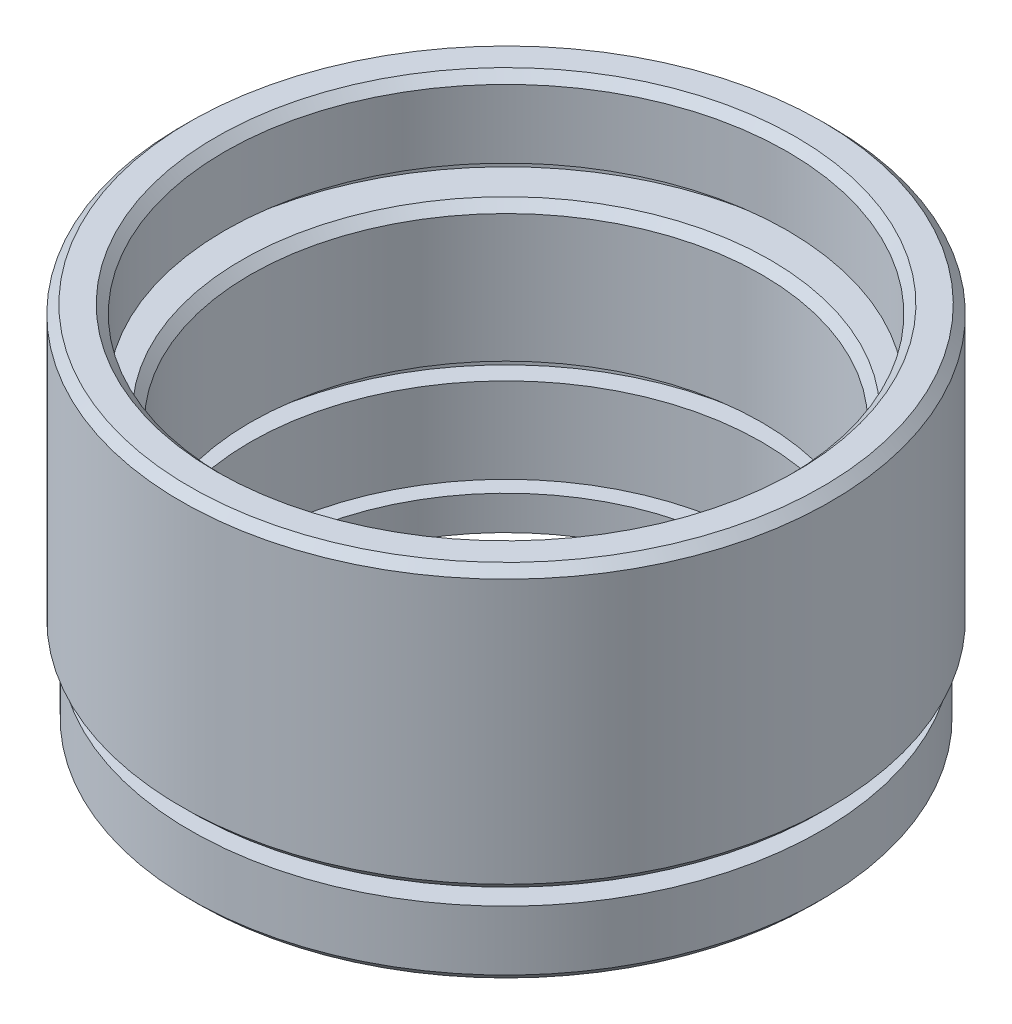
from build123d import *

# Parameters (mm, degrees)
CHAMFER_1_SIZE = 0.5


with BuildPart() as part:
    # 草图1 → 旋转1 (revolve)
    with BuildSketch(Plane.XY, mode=Mode.PRIVATE) as revolve_1_sk:
        Polygon((14, 0), (14, 2), (15, 2), (15, 7), (16.15, 7), (16.15, 8), (15, 8), (15, 16), (17.65, 16), (17.65, 17), (16.5, 17), (16.5, 21.5), (18.55, 21.5), (19.05, 21), (19.05, 5.5), (18.55, 5), (17, 5), (17, 4), (18.5, 4), (18.5, 0.5), (18, 0), align=None)
    revolve(revolve_1_sk.sketch.rotate(Axis((0, 0, 0), (0, 1, 0)), 90), axis=Axis((0, 0, 0), (0, 1, 0)))  # turned: the seam where the file's is

    # 倒角1
    chamfer_1_edges = [part.edges().sort_by_distance(p)[0] for p in [
        (0, 16, 15),
        (0, 21.5, 16.5),
    ]]
    chamfer(chamfer_1_edges, length=CHAMFER_1_SIZE)


solid = part.part
